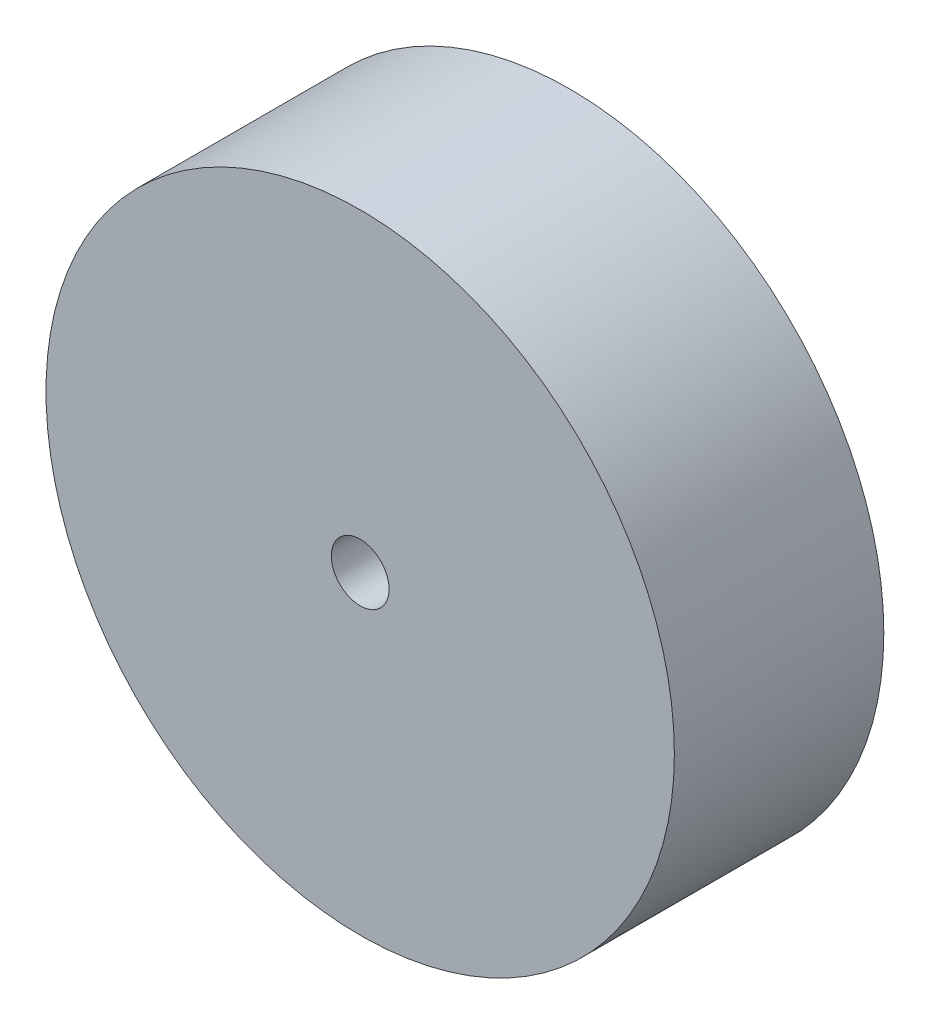
from build123d import *

# Parameters (mm, degrees)
ESQUISSE1_R        = 19.05
ESQUISSE1_R_2      = 1.75
BOSS_EXTRU_1_DEPTH = 12.7


with BuildPart() as part:
    # Esquisse1 → Boss.-Extru.1 (new body)
    with BuildSketch(Plane.XY):
        Circle(ESQUISSE1_R)
        Circle(ESQUISSE1_R_2, mode=Mode.SUBTRACT)
    extrude(amount=BOSS_EXTRU_1_DEPTH)


solid = part.part
